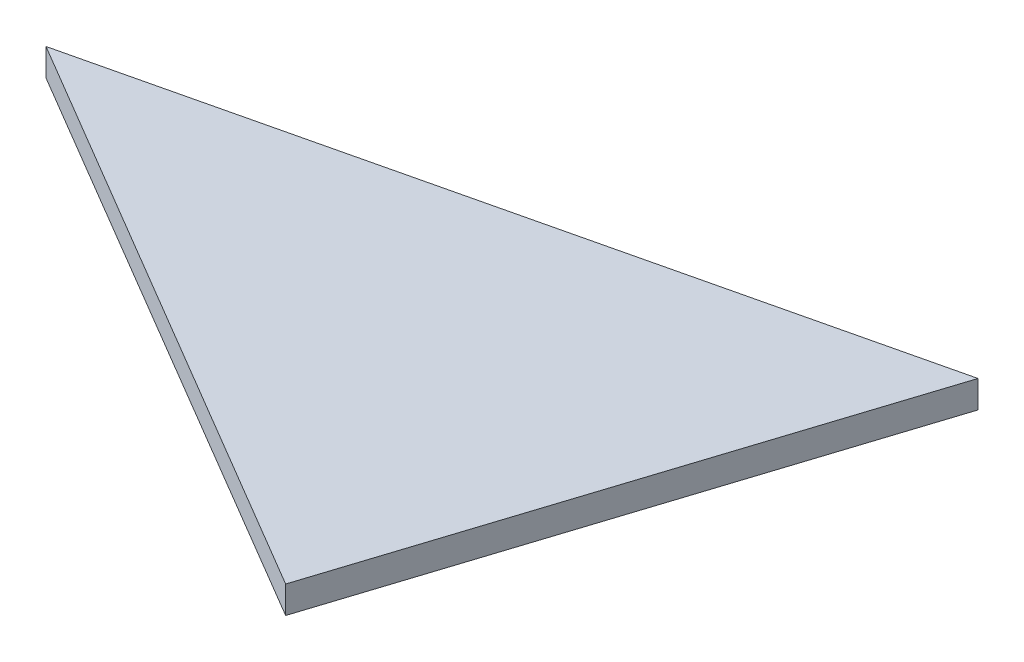
from build123d import *

# Parameters (mm, degrees)
BOSS_EXTRU_1_DEPTH = 2


with BuildPart() as part:
    # Esquisse1 → Boss.-Extru.1 (new body)
    with BuildSketch(Plane(origin=(0, 0, 0), x_dir=(1, 0, 0), z_dir=(0, 1, 0))):
        Polygon((55.244252175, 13.087302851), (0, 0), (42.915081112, -25.344344797), align=None)
    extrude(amount=BOSS_EXTRU_1_DEPTH)


solid = part.part
